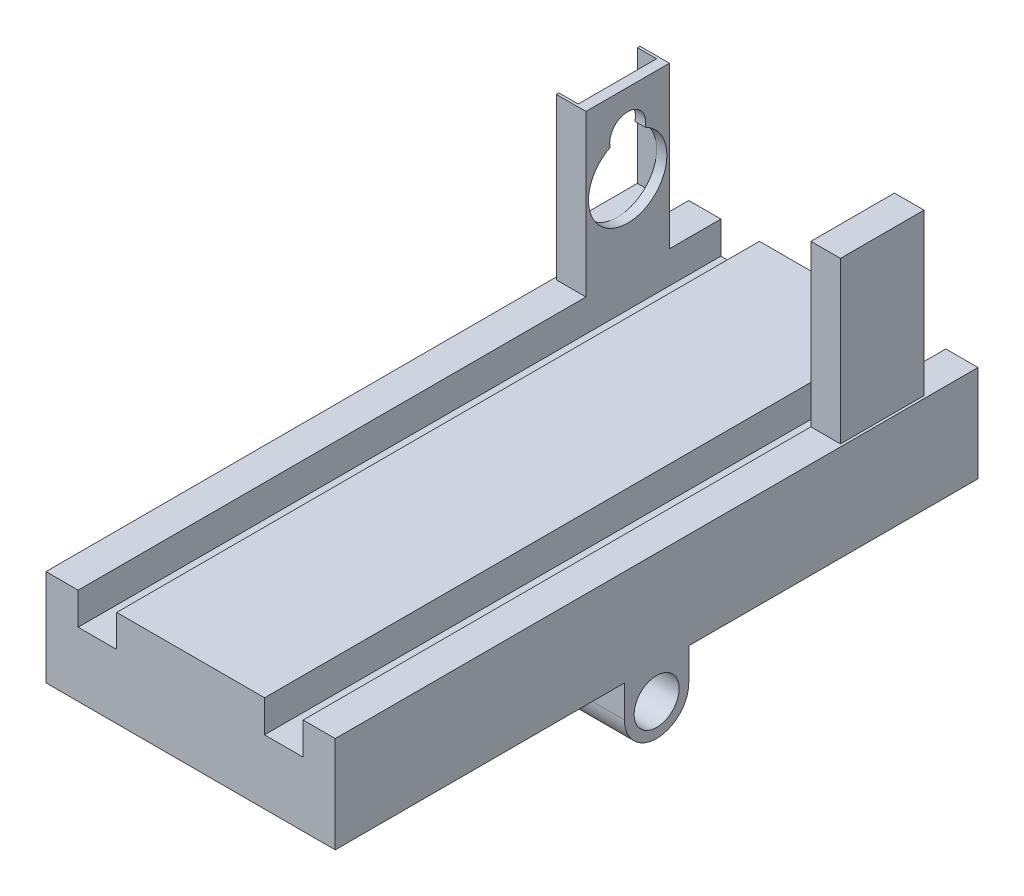
from build123d import *

# Parameters (mm, degrees)
BOSS_EXTRUDE1_DEPTH = 100
SKETCH2_W           = 10
SKETCH2_H           = 5
BOSS_EXTRUDE3_DEPTH = 45
SKETCH3_R           = 5
BOSS_EXTRUDE4_DEPTH = 45
SKETCH4_R           = 3.5
CUT_EXTRUDE1_DEPTH  = 45
SKETCH5_W           = 4.6
SKETCH5_H           = 13
BOSS_EXTRUDE5_DEPTH = 25
SKETCH6_R           = 6.1
SKETCH6_R_2         = 2.8
CUT_EXTRUDE2_DEPTH  = 25
SKETCH7_W           = 12.2
SKETCH7_H           = 22.5
CUT_EXTRUDE3_DEPTH  = 3


with BuildPart() as part:
    # Sketch1 → Boss-Extrude1 (new body)
    with BuildSketch(Plane.XY):
        Polygon((-11.5, 5), (11.5, 5), (11.5, 0), (17.5, 0), (17.5, 5), (22.5, 5), (22.5, -10), (-22.5, -10), (-22.5, 5), (-17.5, 5), (-17.5, 0), (-11.5, 0), align=None)
    extrude(amount=BOSS_EXTRUDE1_DEPTH)

    # Sketch2 → Boss-Extrude3 (add)
    with BuildSketch(Plane.ZY.offset(22.5)):
        with Locations((50, -12.5)):
            Rectangle(SKETCH2_W, SKETCH2_H)
    extrude(amount=-BOSS_EXTRUDE3_DEPTH)

    # Sketch3 → Boss-Extrude4 (add)
    with BuildSketch(Plane.ZY.offset(22.5)):
        with Locations((50, -15)):
            Circle(SKETCH3_R)
    extrude(amount=-BOSS_EXTRUDE4_DEPTH)

    # Sketch4 → Cut-Extrude1 (cut)
    with BuildSketch(Plane.ZY.offset(22.5)):
        with Locations((50, -15)):
            Circle(SKETCH4_R)
    extrude(amount=-CUT_EXTRUDE1_DEPTH, mode=Mode.SUBTRACT)

    # Sketch5 → Boss-Extrude5 (add)
    with BuildSketch(Plane(origin=(0, 5, 0), x_dir=(1, 0, 0), z_dir=(0, 1, 0))):
        with Locations((-19.8, -14.5)):
            Rectangle(SKETCH5_W, SKETCH5_H)
        with Locations((19.8, -14.5)):
            Rectangle(SKETCH5_W, SKETCH5_H)
    extrude(amount=BOSS_EXTRUDE5_DEPTH)

    # Sketch6 → Cut-Extrude2 (cut)
    with BuildSketch(Plane(origin=(-17.5, 0, 0), x_dir=(0, 0, -1), z_dir=(1, 0, 0))):
        with Locations((-14.5, 17.8)):
            Circle(SKETCH6_R)
        with Locations((-14.5, 23.9)):
            Circle(SKETCH6_R_2)
    extrude(amount=-CUT_EXTRUDE2_DEPTH, mode=Mode.SUBTRACT)

    # Sketch7 → Cut-Extrude3 (cut)
    with BuildSketch(Plane.ZY.offset(22.1)):
        with Locations((14.5, 22.95)):
            Rectangle(SKETCH7_W, SKETCH7_H)
    extrude(amount=-CUT_EXTRUDE3_DEPTH, mode=Mode.SUBTRACT)


solid = part.part
